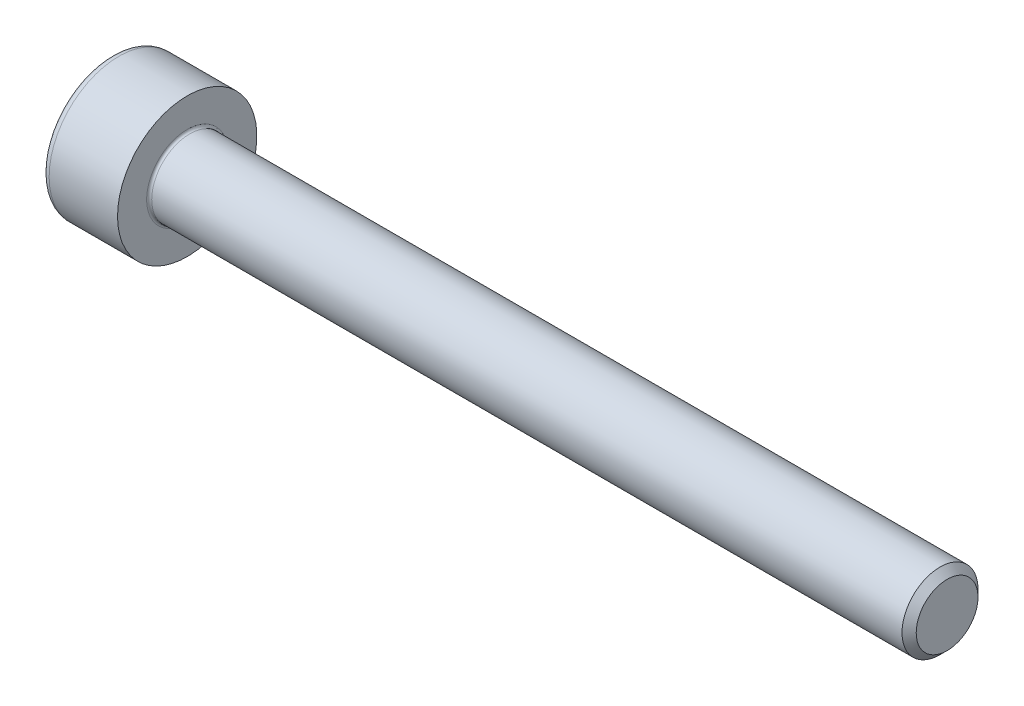
from build123d import *

# Parameters (mm, degrees)
FILLET1_R   = 0.1
FILLET2_R   = 0.3
HEX_2_DEPTH = 1.3


with BuildPart() as part:
    # BodySke → Base-Revolve (revolve)
    with BuildSketch(Plane.XY):
        Polygon((0, 0), (0, 2.75), (3, 2.75), (3, 1.5), (32.7195, 1.5), (33, 1.2195), (33, 0), align=None)
    revolve(axis=Axis((-31.75, 0, 0), (1, 0, 0)))

    # Fillet1
    fillet1_edges = [part.edges().sort_by_distance(p)[0] for p in [
        (3, -1.5, 0),
    ]]
    fillet(fillet1_edges, radius=FILLET1_R)

    # Fillet2
    fillet2_edges = [part.edges().sort_by_distance(p)[0] for p in [
        (0, -2.75, 0),
    ]]
    fillet(fillet2_edges, radius=FILLET2_R)

    # Sketch2 → Hex-PreBroach (revolve, cut)
    with BuildSketch(Plane.XY):
        Polygon((0, 1.26), (1.3, 1.26), (2.027461339, 0), (0, 0), align=None)
    revolve(axis=Axis((0, 0, 0), (1, 0, 0)), mode=Mode.SUBTRACT)

    # Sketch3 → Hex 2 (cut)
    with BuildSketch(Plane(origin=(0, 0, 0), x_dir=(0, 0.5, 0.866025404), z_dir=(-1, 0, 0))):
        Polygon((0.727461339, 1.26), (-0.727461339, 1.26), (-1.454922678, 0), (-0.727461339, -1.26), (0.727461339, -1.26), (1.454922678, 0), align=None)
    extrude(amount=-HEX_2_DEPTH, mode=Mode.SUBTRACT)


solid = part.part
